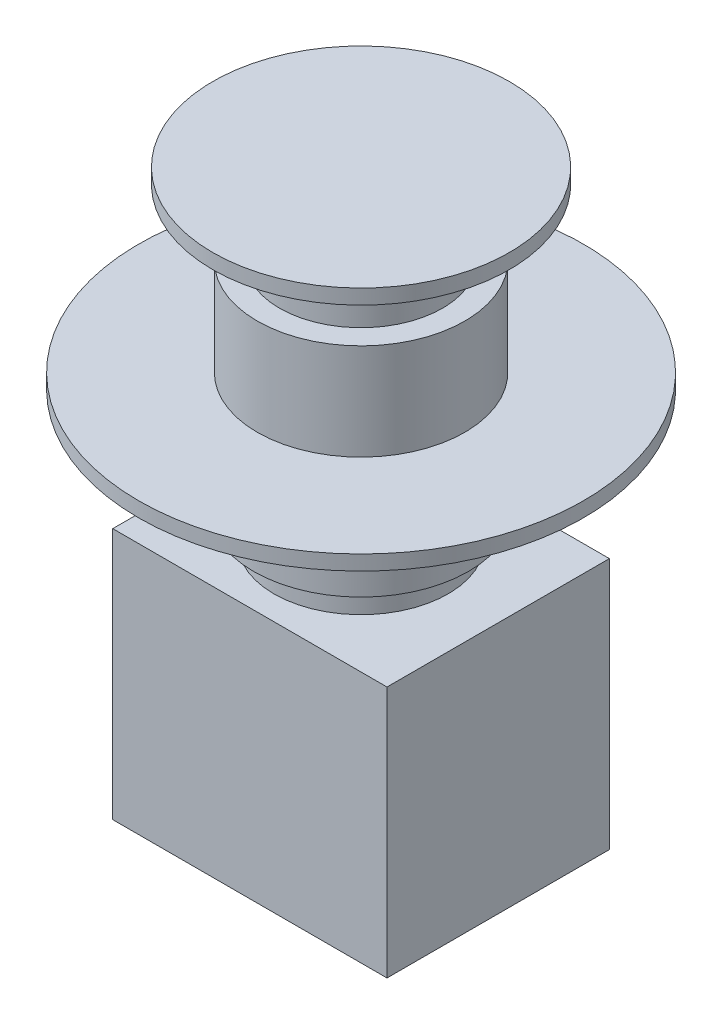
from build123d import *

# Parameters (mm, degrees)
ESBO_O1_W                = 37
ESBO_O1_H                = 30
RESSALTO_EXTRUS_O1_DEPTH = 34
ESBO_O2_R                = 11.75
RESSALTO_EXTRUS_O2_DEPTH = 4
ESBO_O3_R                = 14.5
RESSALTO_EXTRUS_O3_DEPTH = 8
ESBO_O4_R                = 13
RESSALTO_EXTRUS_O4_DEPTH = 1
ESBO_O5_R                = 11
RESSALTO_EXTRUS_O5_DEPTH = 5
ESBO_O6_R                = 30
RESSALTO_EXTRUS_O6_DEPTH = 2
ESBO_O7_R                = 14
RESSALTO_EXTRUS_O7_DEPTH = 13
ESBO_O8_R                = 11
RESSALTO_EXTRUS_O8_DEPTH = 9
ESBO_O9_R                = 20
RESSALTO_EXTRUS_O9_DEPTH = 2


with BuildPart() as part:
    # Esboço1 → Ressalto-extrusão1 (new body)
    with BuildSketch(Plane(origin=(0, 0, 0), x_dir=(1, 0, 0), z_dir=(0, 1, 0))):
        Rectangle(ESBO_O1_W, ESBO_O1_H)
    extrude(amount=RESSALTO_EXTRUS_O1_DEPTH)

    # Esboço2 → Ressalto-extrusão2 (add)
    with BuildSketch(Plane(origin=(0, 34, 0), x_dir=(1, 0, 0), z_dir=(0, 1, 0))):
        Circle(ESBO_O2_R)
    extrude(amount=RESSALTO_EXTRUS_O2_DEPTH)

    # Esboço3 → Ressalto-extrusão3 (add)
    with BuildSketch(Plane(origin=(0, 38, 0), x_dir=(1, 0, 0), z_dir=(0, 1, 0))):
        Circle(ESBO_O3_R)
    extrude(amount=RESSALTO_EXTRUS_O3_DEPTH)

    # Esboço4 → Ressalto-extrusão4 (add)
    with BuildSketch(Plane(origin=(0, 46, 0), x_dir=(1, 0, 0), z_dir=(0, 1, 0))):
        Circle(ESBO_O4_R)
    extrude(amount=RESSALTO_EXTRUS_O4_DEPTH)

    # Esboço5 → Ressalto-extrusão5 (add)
    with BuildSketch(Plane(origin=(0, 47, 0), x_dir=(1, 0, 0), z_dir=(0, 1, 0))):
        Circle(ESBO_O5_R)
    extrude(amount=RESSALTO_EXTRUS_O5_DEPTH)

    # Esboço6 → Ressalto-extrusão6 (add)
    with BuildSketch(Plane(origin=(0, 52, 0), x_dir=(1, 0, 0), z_dir=(0, 1, 0))):
        Circle(ESBO_O6_R)
    extrude(amount=RESSALTO_EXTRUS_O6_DEPTH)

    # Esboço7 → Ressalto-extrusão7 (add)
    with BuildSketch(Plane(origin=(0, 54, 0), x_dir=(1, 0, 0), z_dir=(0, 1, 0))):
        Circle(ESBO_O7_R)
    extrude(amount=RESSALTO_EXTRUS_O7_DEPTH)

    # Esboço8 → Ressalto-extrusão8 (add)
    with BuildSketch(Plane(origin=(0, 67, 0), x_dir=(1, 0, 0), z_dir=(0, 1, 0))):
        Circle(ESBO_O8_R)
    extrude(amount=RESSALTO_EXTRUS_O8_DEPTH)

    # Esboço9 → Ressalto-extrusão9 (add)
    with BuildSketch(Plane(origin=(0, 76, 0), x_dir=(1, 0, 0), z_dir=(0, 1, 0))):
        Circle(ESBO_O9_R)
    extrude(amount=RESSALTO_EXTRUS_O9_DEPTH)


solid = part.part
